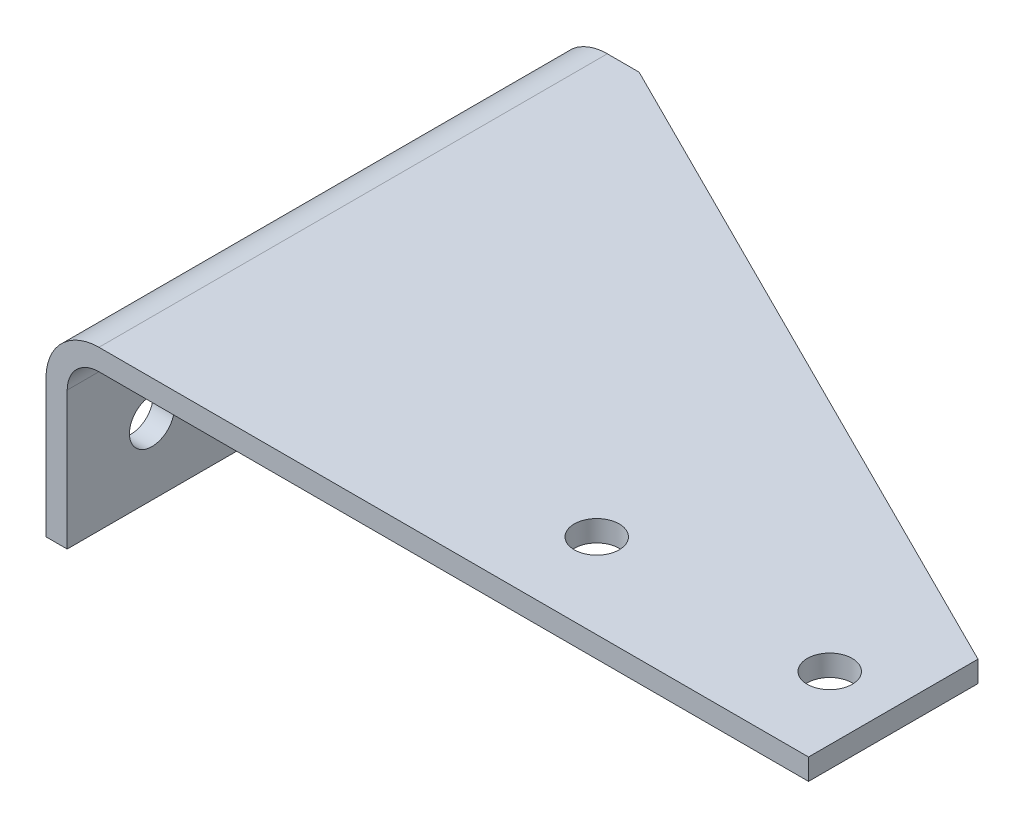
from build123d import *

# Parameters (mm, degrees)
EXTRUDE1_DEPTH         = 127
SKETCH2_R              = 6.731
CUT_CHAMFER_DEPTH      = 508
CUT_CHAMFER_DEPTH_BACK = 58.15
SKETCH3_R              = 6.731
CUT_HOLES_DEPTH        = 229.6
CUT_LH_001_DEPTH       = 58.15


with BuildPart() as part:
    # Sketch1 → Extrude1 (new body, symmetric)
    with BuildSketch(Plane.XY):
        with BuildLine():
            Line((228.6, 0), (15.875, 0))
            ThreePointArc((15.875, 0), (4.649679849, -4.649679849), (0, -15.875))
            Line((0, -15.875), (0, -57.15))
            Line((0, -57.15), (6.35, -57.15))
            Line((6.35, -57.15), (6.35, -15.875))
            ThreePointArc((6.35, -15.875), (9.139807909, -9.139807909), (15.875, -6.35))
            Line((15.875, -6.35), (228.6, -6.35))
            Line((228.6, -6.35), (228.6, 0))
        make_face()
    extrude(amount=EXTRUDE1_DEPTH, both=True)

    # Sketch2 → Cut-Chamfer (cut, two sides)
    with BuildSketch(Plane(origin=(0, 0, 0), x_dir=(1, 0, 0), z_dir=(0, 1, 0))) as cut_chamfer_sk:
        with Locations((209.55, 0)):
            Circle(SKETCH2_R)
        with Locations((139.7, 0)):
            Circle(SKETCH2_R)
        Polygon((25.4, 127), (228.6, 25.4), (228.6, 127), align=None)
        Polygon((25.4, -127), (228.6, -25.4), (228.6, -127), align=None)
    extrude(amount=CUT_CHAMFER_DEPTH, mode=Mode.SUBTRACT)
    extrude(cut_chamfer_sk.sketch, amount=-CUT_CHAMFER_DEPTH_BACK, mode=Mode.SUBTRACT)

    # Sketch3 → Cut-Holes (cut, through all)
    with BuildSketch(Plane(origin=(0, 0, 0), x_dir=(0, 0, -1), z_dir=(1, 0, 0))):
        with Locations((0, -36.5125)):
            Circle(SKETCH3_R)
        with Locations((101.6, -36.5125)):
            Circle(SKETCH3_R)
        with Locations((0, -150.8125)):
            Circle(SKETCH3_R)
        with Locations((101.6, -150.8125)):
            Circle(SKETCH3_R)
        with Locations((-101.6, -36.5125)):
            Circle(SKETCH3_R)
        with Locations((-101.6, -150.8125)):
            Circle(SKETCH3_R)
    extrude(amount=CUT_HOLES_DEPTH, mode=Mode.SUBTRACT)

    # Sketch5 → Cut LH -001 (cut, through all)
    with BuildSketch(Plane(origin=(0, 0, 0), x_dir=(1, 0, 0), z_dir=(0, 1, 0))):
        Polygon((-579.123087515, -25.4), (-7.348788452, -25.4), (228.6, -25.4), (800.374299063, -25.4), (800.374299063, -1168.948598126), (-579.123087515, -1168.948598126), align=None)
    extrude(amount=-CUT_LH_001_DEPTH, mode=Mode.SUBTRACT)


solid = part.part
